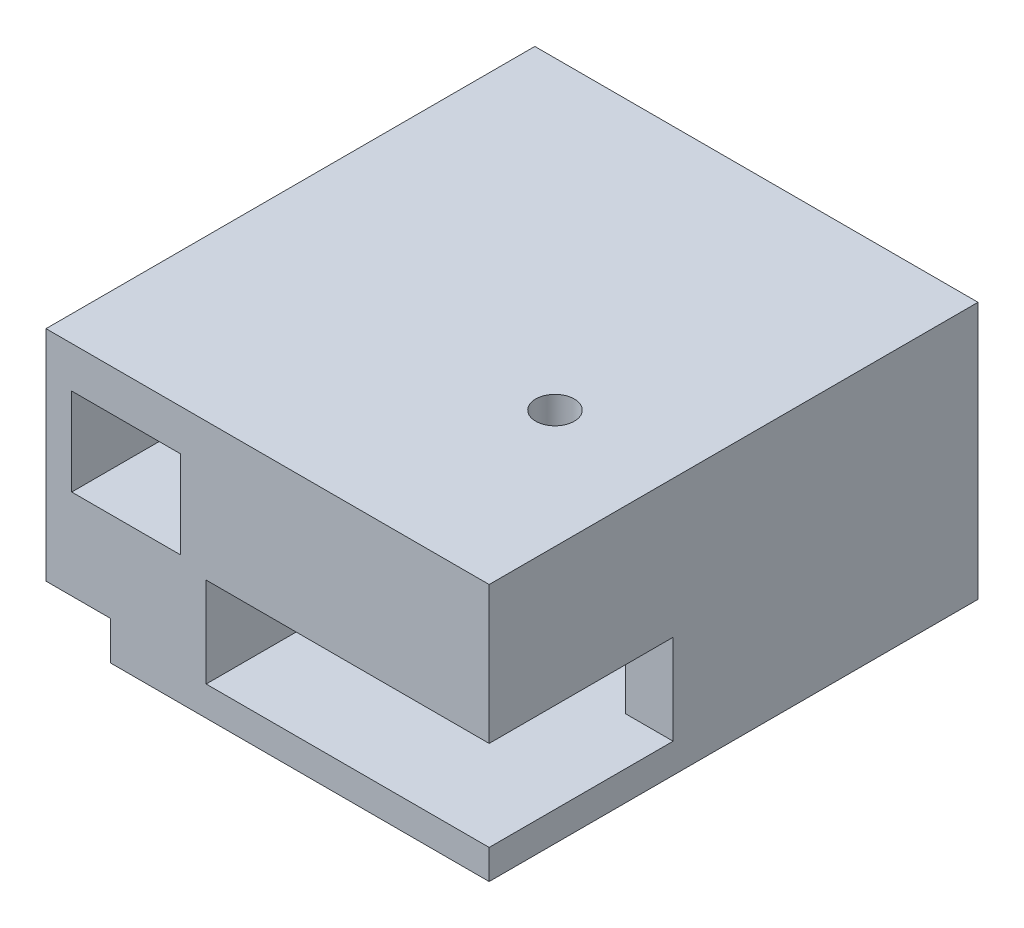
from build123d import *

# Parameters (mm, degrees)
SKETCH1_W                      = 19
SKETCH1_H                      = 10.7
BOSS_EXTRUDE1_DEPTH            = 38
SKETCH1_H_2                    = 2.3
BOSS_EXTRUDE1_2_DEPTH          = 38
SKETCH1_6_W                    = 12.45
SKETCH1_6_H                    = 3.2
BOSS_EXTRUDE6_DEPTH            = 38
BOSS_EXTRUDE7_DEPTH            = 16
SKETCH4_W                      = 38
SKETCH4_H                      = 2.3
SKETCH4_H_2                    = 10.7
BOSS_EXTRUDE8_DEPTH            = 3
CUT_EXTRUDE1_REACH             = 48.286
SKETCH6_R                      = 1.5
CUT_EXTRUDE1_DIRECTION_2_REACH = 48.286
BOSS_EXTRUDE10_REACH           = 45.922
SKETCH7_W                      = 2
SKETCH7_H                      = 38
BOSS_EXTRUDE11_REACH           = 46.087
SKETCH8_W                      = 7.5
SKETCH8_H                      = 38
CUT_EXTRUDE2_REACH             = 55.44
SKETCH9_R                      = 1.5
CUT_EXTRUDE3_START             = -2
SKETCH9_3_R                    = 2.9
SKETCH9_3_R_2                  = 1.5
CUT_EXTRUDE3_DEPTH             = 8.45
SKETCH6_3_R                    = 5.5
SKETCH6_3_R_2                  = 1.5
SKETCH6_3_W                    = 9.18298076
SKETCH6_3_H                    = 14.3
CUT_EXTRUDE4_DEPTH             = 7


with BuildPart() as part:
    # Sketch1 → Boss-Extrude1 (new body)
    with BuildSketch(Plane.XY):
        with Locations((7.125, 9.65)):
            Rectangle(SKETCH1_W, SKETCH1_H)
    extrude(amount=-BOSS_EXTRUDE1_DEPTH)



with BuildPart() as body_2:
    # Sketch1 → Boss-Extrude1 2 (new body)
    with BuildSketch(Plane.XY):
        with Locations((7.125, -3.85)):
            Rectangle(SKETCH1_W, SKETCH1_H_2)
    extrude(amount=-BOSS_EXTRUDE1_2_DEPTH)


with BuildPart() as part_1:
    add(part.part)

    add(body_2.part)  # Boss-Extrude6 merges body 2
    # Sketch1_6 → Boss-Extrude6 (add)
    with BuildSketch(Plane.XY):
        Polygon((-14.825, 5), (-14.825, -2), (-9.825, -2), (-9.825, -5), (-2.375, -5), (-2.375, 5), align=None)
        with Locations((-8.6, 13.4)):
            Rectangle(SKETCH1_6_W, SKETCH1_6_H)
    extrude(amount=-BOSS_EXTRUDE6_DEPTH)

    # Sketch1_7 → Boss-Extrude7 (add)
    with BuildSketch(Plane.XY):
        Polygon((-14.825, -2), (-14.825, -3.3), (-14.825, -5), (-9.825, -5), (-9.825, -2), align=None)
    extrude(amount=-BOSS_EXTRUDE7_DEPTH)

    # Sketch4 → Boss-Extrude8 (add)
    with BuildSketch(Plane(origin=(16.625, 0, 0), x_dir=(0, 0, -1), z_dir=(1, 0, 0))):
        with Locations((19, -3.85)):
            Rectangle(SKETCH4_W, SKETCH4_H)
        with Locations((19, 9.65)):
            Rectangle(SKETCH4_W, SKETCH4_H_2)
    extrude(amount=BOSS_EXTRUDE8_DEPTH)

    # Sketch6 → Cut-Extrude1 (cut, up to next)
    with BuildSketch(Plane(origin=(0, -2.7, 0), x_dir=(1, 0, 0), z_dir=(0, 1, 0)), mode=Mode.PRIVATE) as cut_extrude1_sk1:
        with Locations(Location((10.44201924, 23.7, 0), (0, 0, 270))):
            Circle(SKETCH6_R)
    cut_extrude1_tool1 = extrude(cut_extrude1_sk1.sketch, amount=-CUT_EXTRUDE1_REACH, mode=Mode.PRIVATE) & part_1.part
    # Sketch6 → Cut-Extrude1 (cut, up to next)
    with BuildSketch(Plane(origin=(0, -2.7, 0), x_dir=(1, 0, 0), z_dir=(0, 1, 0)), mode=Mode.PRIVATE) as cut_extrude1_sk2:
        with BuildLine():
            Line((10.44201924, 25.2), (10.44201924, 23.7))
            Line((10.44201924, 23.7), (11.94201924, 23.7))
            ThreePointArc((11.94201924, 23.7), (11.502679412, 24.760660172), (10.44201924, 25.2))
        make_face()
    cut_extrude1_tool2 = extrude(cut_extrude1_sk2.sketch, amount=-CUT_EXTRUDE1_REACH, mode=Mode.PRIVATE) & part_1.part
    # Sketch6 → Cut-Extrude1 (cut, up to next)
    with BuildSketch(Plane(origin=(0, -2.7, 0), x_dir=(1, 0, 0), z_dir=(0, 1, 0)), mode=Mode.PRIVATE) as cut_extrude1_sk3:
        with BuildLine():
            Line((11.94201924, 23.7), (10.44201924, 23.7))
            Line((10.44201924, 23.7), (10.44201924, 25.2))
            ThreePointArc((10.44201924, 25.2), (9.381359068, 22.639339828), (11.94201924, 23.7))
        make_face()
    cut_extrude1_tool3 = extrude(cut_extrude1_sk3.sketch, amount=-CUT_EXTRUDE1_REACH, mode=Mode.PRIVATE) & part_1.part
    add(cut_extrude1_tool1.solids().sort_by_distance((10.442019, -2.7, -23.7))[0], mode=Mode.SUBTRACT)
    add(cut_extrude1_tool2.solids().sort_by_distance((11.078639, -2.7, -24.33662))[0], mode=Mode.SUBTRACT)
    add(cut_extrude1_tool3.solids().sort_by_distance((10.229813, -2.7, -23.487793))[0], mode=Mode.SUBTRACT)

    # Cut-Extrude1 direction 2: up to this face of the body (flat: up to its plane)
    cut_extrude1_direction_2_end = Plane(part_1.part.faces().sort_by_distance((2.4, 15, -19))[0])
    # Sketch6 → Cut-Extrude1 direction 2 (cut, up to the picked face)
    with BuildSketch(Plane(origin=(0, -2.7, 0), x_dir=(1, 0, 0), z_dir=(0, 1, 0)), mode=Mode.PRIVATE) as cut_extrude1_direction_2_sk1:
        with Locations(Location((10.44201924, 23.7, 0), (0, 0, 270))):
            Circle(SKETCH6_R)
    cut_extrude1_direction_2_tool1 = split(extrude(cut_extrude1_direction_2_sk1.sketch, amount=CUT_EXTRUDE1_DIRECTION_2_REACH, mode=Mode.PRIVATE), bisect_by=cut_extrude1_direction_2_end, keep=Keep.BOTH, mode=Mode.PRIVATE)
    # Sketch6 → Cut-Extrude1 direction 2 (cut, up to the picked face)
    with BuildSketch(Plane(origin=(0, -2.7, 0), x_dir=(1, 0, 0), z_dir=(0, 1, 0)), mode=Mode.PRIVATE) as cut_extrude1_direction_2_sk2:
        with BuildLine():
            Line((10.44201924, 25.2), (10.44201924, 23.7))
            Line((10.44201924, 23.7), (11.94201924, 23.7))
            ThreePointArc((11.94201924, 23.7), (11.502679412, 24.760660172), (10.44201924, 25.2))
        make_face()
    cut_extrude1_direction_2_tool2 = split(extrude(cut_extrude1_direction_2_sk2.sketch, amount=CUT_EXTRUDE1_DIRECTION_2_REACH, mode=Mode.PRIVATE), bisect_by=cut_extrude1_direction_2_end, keep=Keep.BOTH, mode=Mode.PRIVATE)
    # Sketch6 → Cut-Extrude1 direction 2 (cut, up to the picked face)
    with BuildSketch(Plane(origin=(0, -2.7, 0), x_dir=(1, 0, 0), z_dir=(0, 1, 0)), mode=Mode.PRIVATE) as cut_extrude1_direction_2_sk3:
        with BuildLine():
            Line((11.94201924, 23.7), (10.44201924, 23.7))
            Line((10.44201924, 23.7), (10.44201924, 25.2))
            ThreePointArc((10.44201924, 25.2), (9.381359068, 22.639339828), (11.94201924, 23.7))
        make_face()
    cut_extrude1_direction_2_tool3 = split(extrude(cut_extrude1_direction_2_sk3.sketch, amount=CUT_EXTRUDE1_DIRECTION_2_REACH, mode=Mode.PRIVATE), bisect_by=cut_extrude1_direction_2_end, keep=Keep.BOTH, mode=Mode.PRIVATE)
    add(cut_extrude1_direction_2_tool1.solids().sort_by(Axis((10.442019, -2.7, -23.7), (0, 1, 0)))[0], mode=Mode.SUBTRACT)
    add(cut_extrude1_direction_2_tool2.solids().sort_by(Axis((11.078639, -2.7, -24.33662), (0, 1, 0)))[0], mode=Mode.SUBTRACT)
    add(cut_extrude1_direction_2_tool3.solids().sort_by(Axis((10.229813, -2.7, -23.487793), (0, 1, 0)))[0], mode=Mode.SUBTRACT)

    # Sketch7 → Boss-Extrude10 (add, up to next)
    with BuildSketch(Plane(origin=(0, 5, 0), x_dir=(1, 0, 0), z_dir=(0, 1, 0)), mode=Mode.PRIVATE) as boss_extrude10_sk1:
        with Locations((-3.375, 19)):
            Rectangle(SKETCH7_W, SKETCH7_H)
    boss_extrude10_tool1 = extrude(boss_extrude10_sk1.sketch, amount=BOSS_EXTRUDE10_REACH, mode=Mode.PRIVATE) - part_1.part
    # Sketch7 → Boss-Extrude10 (add, up to next)
    with BuildSketch(Plane(origin=(0, 5, 0), x_dir=(1, 0, 0), z_dir=(0, 1, 0)), mode=Mode.PRIVATE) as boss_extrude10_sk2:
        with Locations((-13.825, 19)):
            Rectangle(SKETCH7_W, SKETCH7_H)
    boss_extrude10_tool2 = extrude(boss_extrude10_sk2.sketch, amount=BOSS_EXTRUDE10_REACH, mode=Mode.PRIVATE) - part_1.part
    add(boss_extrude10_tool1.solids().sort_by_distance((-3.375, 5, -19))[0])
    add(boss_extrude10_tool2.solids().sort_by_distance((-13.825, 5, -19))[0])

    # Sketch8 → Boss-Extrude11 (add, up to next)
    with BuildSketch(Plane.XZ.offset(-4.3), mode=Mode.PRIVATE) as boss_extrude11_sk1:
        with Locations((15.875, -19)):
            Rectangle(SKETCH8_W, SKETCH8_H)
    boss_extrude11_tool1 = extrude(boss_extrude11_sk1.sketch, amount=BOSS_EXTRUDE11_REACH, mode=Mode.PRIVATE) - part_1.part
    add(boss_extrude11_tool1.solids().sort_by_distance((15.875, 4.3, -19))[0])

    # Sketch9 → Cut-Extrude2 (cut, up to next)
    with BuildSketch(Plane.ZY.offset(14.825), mode=Mode.PRIVATE) as cut_extrude2_sk1:
        with Locations(Location((-5.5, 6.75, 0), (0, 0, 270))):
            Circle(SKETCH9_R)
    cut_extrude2_tool1 = extrude(cut_extrude2_sk1.sketch, amount=-CUT_EXTRUDE2_REACH, mode=Mode.PRIVATE) & part_1.part
    add(cut_extrude2_tool1.solids().sort_by_distance((-14.825, 6.75, -5.5))[0], mode=Mode.SUBTRACT)

    # Sketch9_3 → Cut-Extrude3 (cut)
    with BuildSketch(Plane.ZY.offset(14.825).offset(CUT_EXTRUDE3_START)):
        with Locations((-5.5, 6.75)):
            Circle(SKETCH9_3_R)
        with Locations(Location((-5.5, 6.75, 0), (0, 0, 270))):
            Circle(SKETCH9_3_R_2, mode=Mode.SUBTRACT)
    extrude(amount=-CUT_EXTRUDE3_DEPTH, mode=Mode.SUBTRACT)

    # Sketch6_3 → Cut-Extrude4 (cut)
    with BuildSketch(Plane(origin=(0, -2.7, 0), x_dir=(1, 0, 0), z_dir=(0, 1, 0))):
        with Locations((10.44201924, 23.7)):
            Circle(SKETCH6_3_R)
        with Locations(Location((10.44201924, 23.7, 0), (0, 0, 270))):
            Circle(SKETCH6_3_R_2, mode=Mode.SUBTRACT)
        with Locations((15.03350962, 30.85)):
            Rectangle(SKETCH6_3_W, SKETCH6_3_H)
    extrude(amount=CUT_EXTRUDE4_DEPTH, mode=Mode.SUBTRACT)


with BuildPart() as body_2_2:
    # Mirror2: mirrored copy
    add(part_1.part.mirror(Plane.XY))


solid = body_2_2.part
